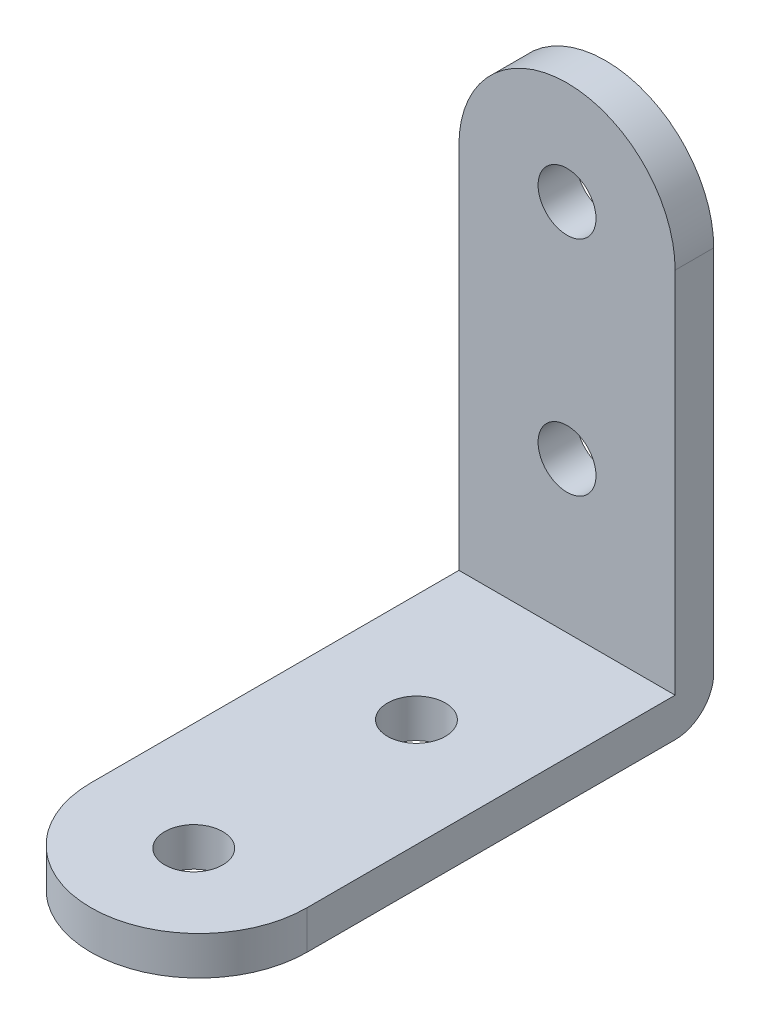
from build123d import *

# Parameters (mm, degrees)
SKETCH1_R           = 2.25
BOSS_EXTRUDE1_DEPTH = 3
CIRPATTERN1_COUNT   = 2
CIRPATTERN1_ANGLE   = 90
FILLET1_R           = 3


with BuildPart() as part:
    # Sketch1 → Boss-Extrude1 (new body)
    with BuildSketch(Plane.XY):
        with BuildLine():
            Line((-8.4, 15.8), (-8.4, -15.8))
            Line((-8.4, -15.8), (8.4, -15.8))
            Line((8.4, -15.8), (8.4, 15.8))
            ThreePointArc((8.4, 15.8), (0, 24.2), (-8.4, 15.8))
        make_face()
        with Locations((0, 16.2)):
            Circle(SKETCH1_R, mode=Mode.SUBTRACT)
        with Locations((0, -1.1)):
            Circle(SKETCH1_R, mode=Mode.SUBTRACT)
    boss_extrude1 = extrude(amount=BOSS_EXTRUDE1_DEPTH)

    # CirPattern1: Boss-Extrude1 ×2 about axis
    cirpattern1_axis = Axis((-9.24, -14.3, 1.5), (1, 0, 0))
    for i in range(1, CIRPATTERN1_COUNT):
        add(boss_extrude1.rotate(cirpattern1_axis, i * CIRPATTERN1_ANGLE / (CIRPATTERN1_COUNT - 1)))

    # Fillet1
    fillet1_edges = [part.edges().sort_by_distance(p)[0] for p in [
        (0, -15.8, 0),
    ]]
    fillet(fillet1_edges, radius=FILLET1_R)


solid = part.part
